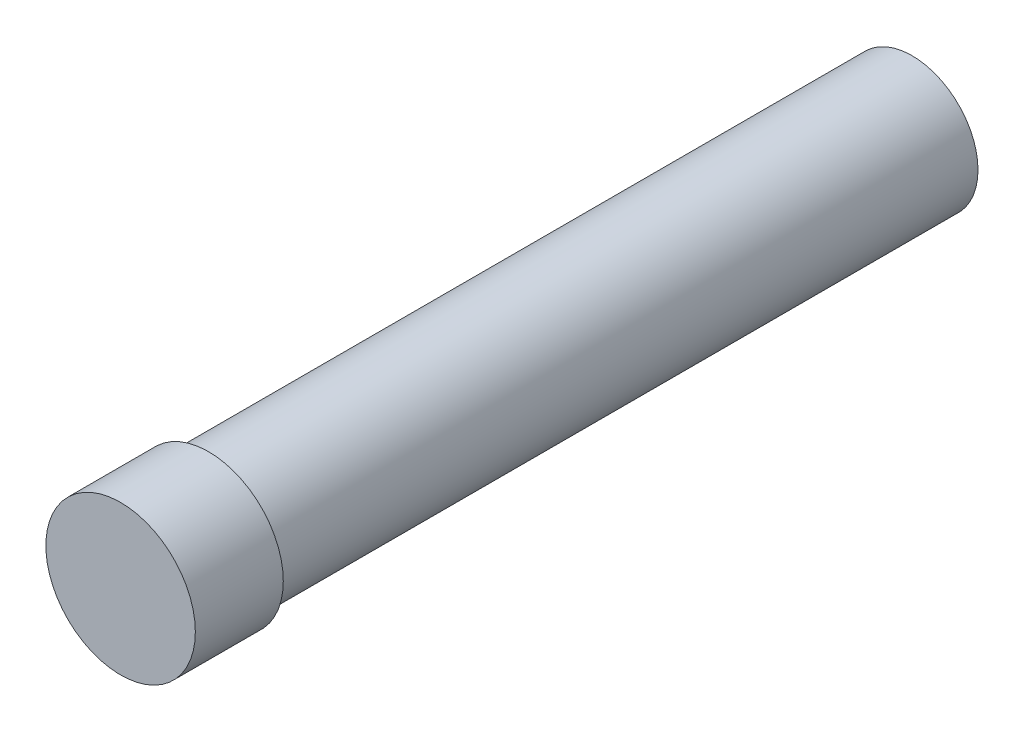
from build123d import *

# Parameters (mm, degrees)
IZIM1_R                     = 75
Y_KSEKLIK_EKSTR_ZYON1_DEPTH = 800
IZIM2_R                     = 85
Y_KSEKLIK_EKSTR_ZYON2_DEPTH = 100


with BuildPart() as part:
    # Çizim1 → Yükseklik-Ekstrüzyon1 (new body)
    with BuildSketch(Plane.XY):
        Circle(IZIM1_R)
    extrude(amount=Y_KSEKLIK_EKSTR_ZYON1_DEPTH)

    # Çizim2 → Yükseklik-Ekstrüzyon2 (add)
    with BuildSketch(Plane.XY.offset(800)):
        Circle(IZIM2_R)
    extrude(amount=Y_KSEKLIK_EKSTR_ZYON2_DEPTH)


solid = part.part
